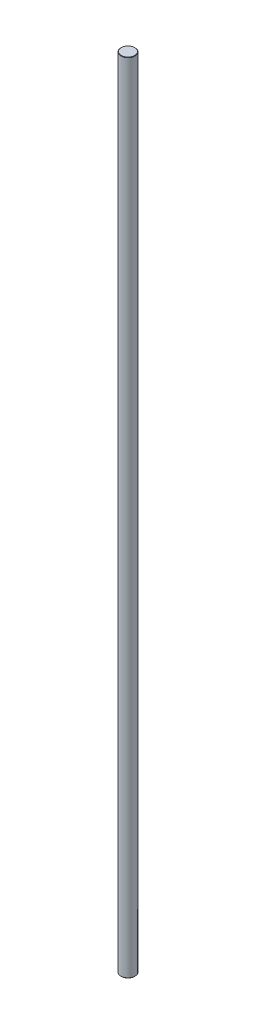
from build123d import *

# Parameters (mm, degrees)
SKETCH1_R           = 4
BOSS_EXTRUDE1_DEPTH = 225
CHAMFER1_SIZE       = 0.2


with BuildPart() as part:
    # Sketch1 → Boss-Extrude1 (new body, symmetric)
    with BuildSketch(Plane(origin=(0, 0, 0), x_dir=(1, 0, 0), z_dir=(0, 1, 0))):
        Circle(SKETCH1_R)
    extrude(amount=BOSS_EXTRUDE1_DEPTH, both=True)

    # Chamfer1
    chamfer1_edges = [part.edges().sort_by_distance(p)[0] for p in [
        (-4, -225, 0),
        (-4, 225, 0),
    ]]
    chamfer(chamfer1_edges, length=CHAMFER1_SIZE)


solid = part.part
